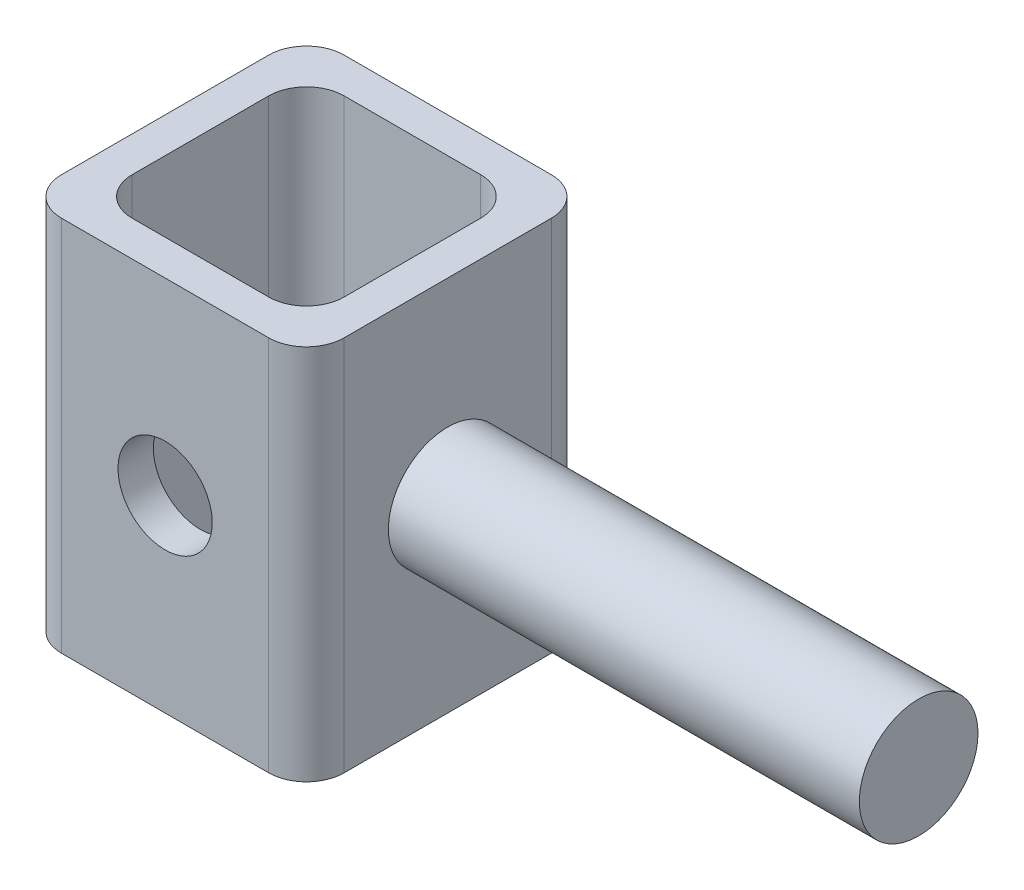
from build123d import *

# Parameters (mm, degrees)
SKETCH1_W           = 19.05
SKETCH1_H           = 19.05
SKETCH1_W_2         = 14.2875
SKETCH1_H_2         = 14.2875
BOSS_EXTRUDE1_DEPTH = 25.4
CUT_EXTRUDE1_REACH  = 21.05
SKETCH2_R           = 3.175
SKETCH3_R           = 4
BOSS_EXTRUDE2_DEPTH = 31.75
FILLET1_R           = 2.54


with BuildPart() as part:
    # Sketch1 → Boss-Extrude1 (new body)
    with BuildSketch(Plane(origin=(0, 0, 0), x_dir=(1, 0, 0), z_dir=(0, 1, 0))):
        with Locations((9.525, 9.525)):
            Rectangle(SKETCH1_W, SKETCH1_H)
        with Locations((9.525, 9.525)):
            Rectangle(SKETCH1_W_2, SKETCH1_H_2, mode=Mode.SUBTRACT)
    extrude(amount=BOSS_EXTRUDE1_DEPTH)

    # Sketch2 → Cut-Extrude1 (cut, up to next)
    with BuildSketch(Plane.XY, mode=Mode.PRIVATE) as cut_extrude1_sk1:
        with Locations((9.525, 12.7)):
            Circle(SKETCH2_R)
    cut_extrude1_tool1 = extrude(cut_extrude1_sk1.sketch, amount=-CUT_EXTRUDE1_REACH, mode=Mode.PRIVATE) & part.part
    add(cut_extrude1_tool1.solids().sort_by_distance((9.525, 12.7, 0))[0], mode=Mode.SUBTRACT)

    # Sketch3 → Boss-Extrude2 (add)
    with BuildSketch(Plane(origin=(19.05, 0, 0), x_dir=(0, 0, -1), z_dir=(1, 0, 0))):
        with Locations((9.525, 12.7)):
            Circle(SKETCH3_R)
    extrude(amount=BOSS_EXTRUDE2_DEPTH)

    # Fillet1
    fillet1_edges = [part.edges().sort_by_distance(p)[0] for p in [
        (2.38125, 12.7, -16.66875),
        (2.38125, 12.7, -2.38125),
        (16.66875, 12.7, -2.38125),
        (16.66875, 12.7, -16.66875),
        (0, 12.7, -19.05),
        (19.05, 12.7, -19.05),
        (19.05, 12.7, 0),
        (0, 12.7, 0),
    ]]
    fillet(fillet1_edges, radius=FILLET1_R)


solid = part.part
